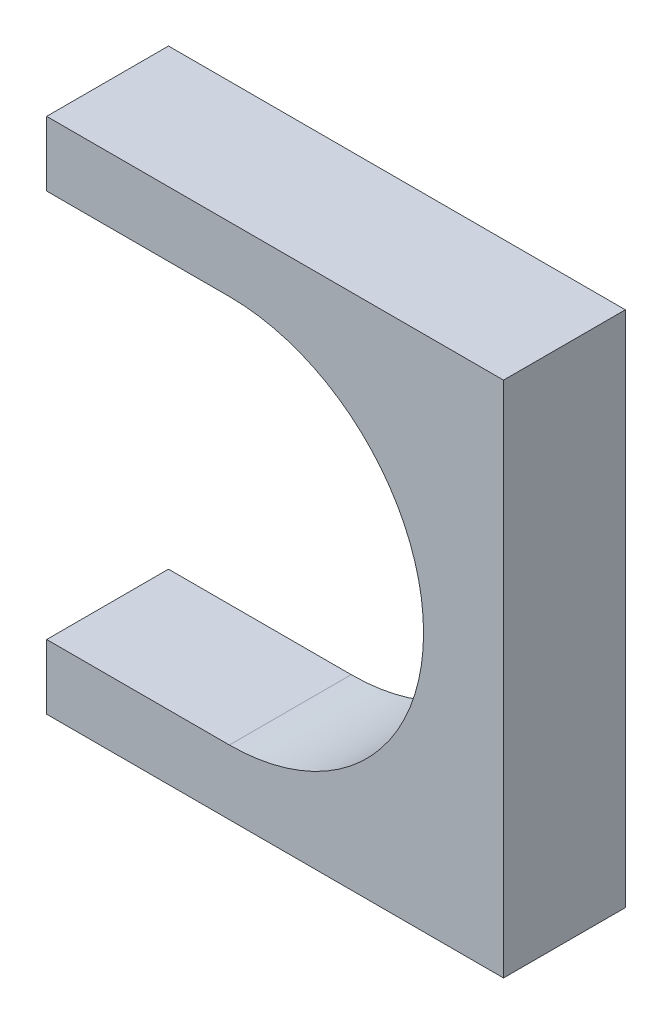
from build123d import *

# Parameters (mm, degrees)
SKETCH_1_R          = 17
EXTRUDE_1_DEPTH     = 8
SKETCH_3_W          = 30
SKETCH_3_H          = 34
EXTRUDE_2_DEPTH     = 8
SKETCH_2_R          = 12.75
CUT_EXTRUDE_1_DEPTH = 8
SKETCH_4_W          = 19.904573782
SKETCH_4_H          = 25.5
CUT_EXTRUDE_2_DEPTH = 8


with BuildPart() as part:
    # 스케치1 → 보스-돌출1 (new body)
    with BuildSketch(Plane.XY):
        Circle(SKETCH_1_R)
    extrude(amount=EXTRUDE_1_DEPTH)

    # 스케치3 → 보스-돌출2 (add)
    with BuildSketch(Plane.XY.offset(8)):
        with Locations((3, 0)):
            Rectangle(SKETCH_3_W, SKETCH_3_H)
    extrude(amount=-EXTRUDE_2_DEPTH)

    # 스케치2 → 컷-돌출1 (cut)
    with BuildSketch(Plane.XY.offset(8)):
        Circle(SKETCH_2_R)
    extrude(amount=-CUT_EXTRUDE_1_DEPTH, mode=Mode.SUBTRACT)

    # 스케치4 → 컷-돌출2 (cut)
    with BuildSketch(Plane(origin=(0, 0, 0), x_dir=(-1, 0, 0), z_dir=(0, 0, -1))):
        with Locations((9.952286891, 0)):
            Rectangle(SKETCH_4_W, SKETCH_4_H)
    extrude(amount=-CUT_EXTRUDE_2_DEPTH, mode=Mode.SUBTRACT)


solid = part.part
